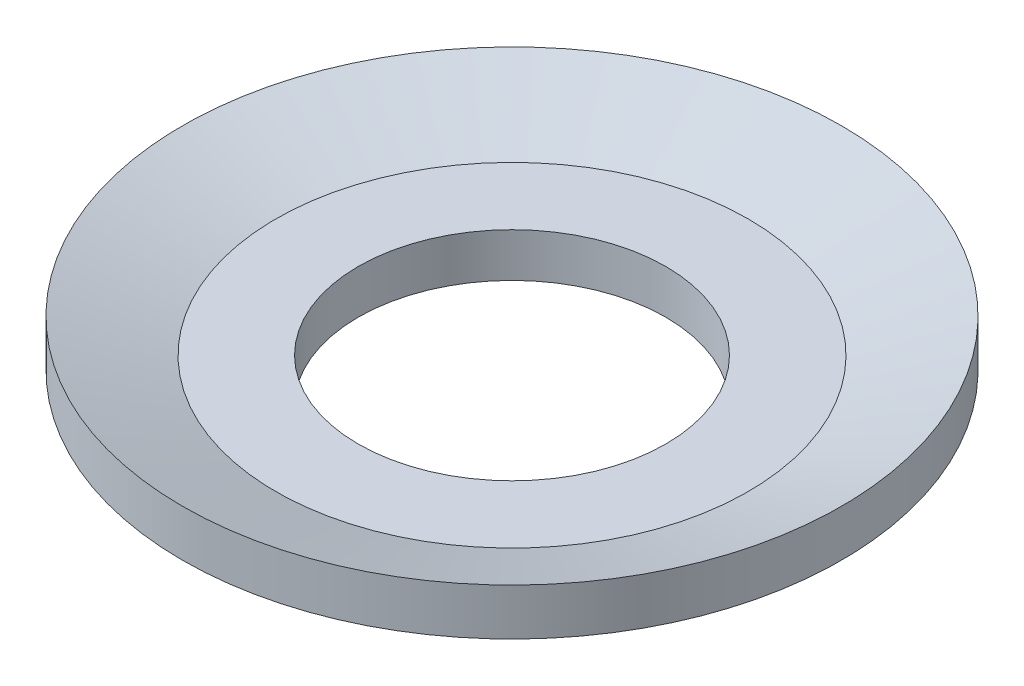
from build123d import *


with BuildPart() as part:
    # Sketch1 → Revolve1 (revolve)
    with BuildSketch(Plane.XY, mode=Mode.PRIVATE) as revolve1_sk:
        with BuildLine():
            Line((2.15, 0.4), (3, 0.709374699))
            Line((3, 0.709374699), (3, 0.28370359))
            Line((3, 0.28370359), (2.286808057, 0.024122952))
            ThreePointArc((2.286808057, 0.024122952), (2.219459271, 0.006076899), (2.15, 0))
            Line((2.15, 0), (1.4, 0))
            Line((1.4, 0), (1.4, 0.4))
            Line((1.4, 0.4), (2.15, 0.4))
        make_face()
    revolve(revolve1_sk.sketch.rotate(Axis((0, 0, 0), (0, 1, 0)), 90), axis=Axis((0, 0, 0), (0, 1, 0)))  # turned: the seam where the file's is


solid = part.part
